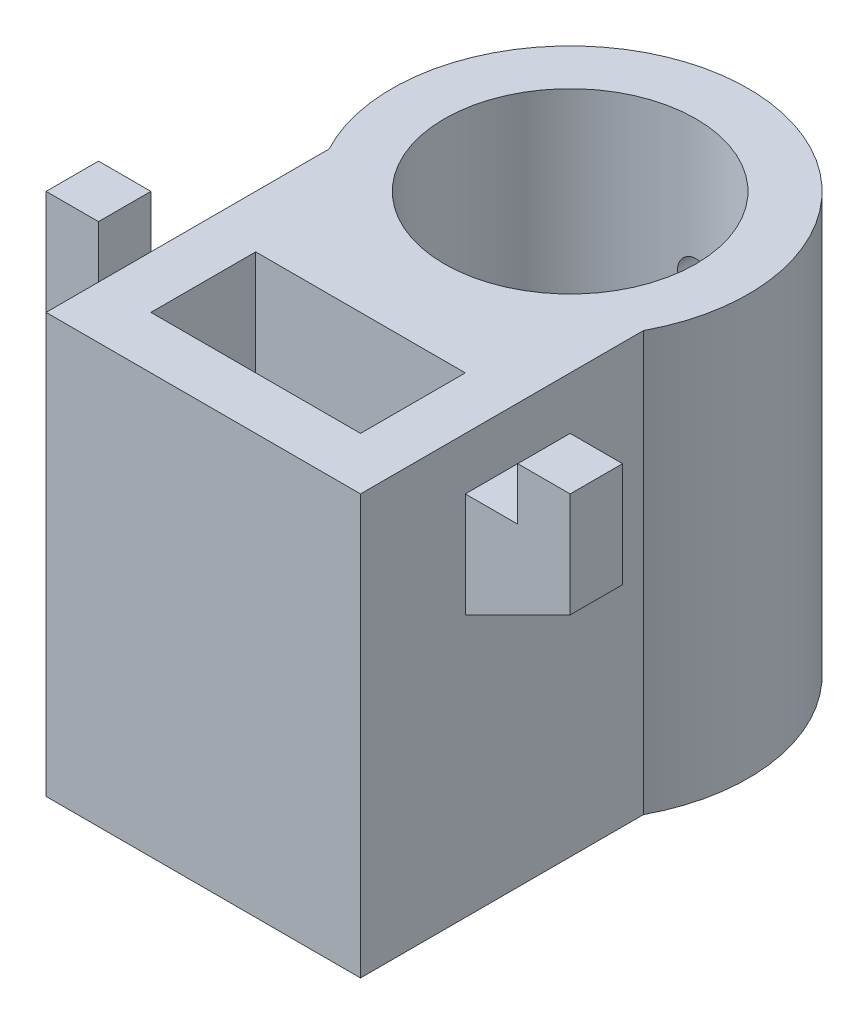
from build123d import *

# Parameters (mm, degrees)
SKETCH1_R           = 7.62
SKETCH1_W           = 12.7
SKETCH1_H           = 6.35
BOSS_EXTRUDE1_DEPTH = 25.4
BOSS_EXTRUDE2_DEPTH = 3.175
CUT_EXTRUDE1_REACH  = 35.02
SKETCH4_R           = 1.0414


with BuildPart() as part:
    # Sketch1 → Boss-Extrude1 (new body)
    with BuildSketch(Plane(origin=(0, 0, 0), x_dir=(1, 0, 0), z_dir=(0, 1, 0))):
        with BuildLine():
            Line((-9.525, -22.225), (9.525, -22.225))
            Line((9.525, -22.225), (9.525, -5.08))
            ThreePointArc((9.525, -5.08), (0, 10.795), (-9.525, -5.08))
            Line((-9.525, -5.08), (-9.525, -22.225))
        make_face()
        Circle(SKETCH1_R, mode=Mode.SUBTRACT)
        with Locations((0, -15.875)):
            Rectangle(SKETCH1_W, SKETCH1_H, mode=Mode.SUBTRACT)
    extrude(amount=BOSS_EXTRUDE1_DEPTH)

    # Sketch3 → Boss-Extrude2 (add)
    with BuildSketch(Plane(origin=(0, 0, 15.875), x_dir=(-1, 0, 0), z_dir=(0, 0, -1))):
        Polygon((-9.525, 22.225), (-9.525, 15.875), (-15.875, 19.05), (-15.875, 25.4), (-12.7, 25.4), (-12.7, 22.225), align=None)
    boss_extrude2 = extrude(amount=BOSS_EXTRUDE2_DEPTH)

    # Mirror1: Boss-Extrude2 across plane
    add(boss_extrude2.mirror(Plane(origin=(0, 0, 0), x_dir=(0, 0, 1), z_dir=(1, 0, 0))))

    # Sketch4 → Cut-Extrude1 (cut, up to next)
    with BuildSketch(Plane(origin=(0, 0, -10.795), x_dir=(-1, 0, 0), z_dir=(0, 0, -1)), mode=Mode.PRIVATE) as cut_extrude1_sk1:
        with Locations((0, 8.382)):
            Circle(SKETCH4_R)
    cut_extrude1_tool1 = extrude(cut_extrude1_sk1.sketch, amount=-CUT_EXTRUDE1_REACH, mode=Mode.PRIVATE) & part.part
    add(cut_extrude1_tool1.solids().sort_by_distance((0, 8.382, -10.795))[0], mode=Mode.SUBTRACT)
    # Sketch4 → Cut-Extrude1 (cut, up to next)
    with BuildSketch(Plane(origin=(0, 0, -10.795), x_dir=(-1, 0, 0), z_dir=(0, 0, -1)), mode=Mode.PRIVATE) as cut_extrude1_sk2:
        with Locations((0, 17.018)):
            Circle(SKETCH4_R)
    cut_extrude1_tool2 = extrude(cut_extrude1_sk2.sketch, amount=-CUT_EXTRUDE1_REACH, mode=Mode.PRIVATE) & part.part
    add(cut_extrude1_tool2.solids().sort_by_distance((0, 17.018, -10.795))[0], mode=Mode.SUBTRACT)


solid = part.part
